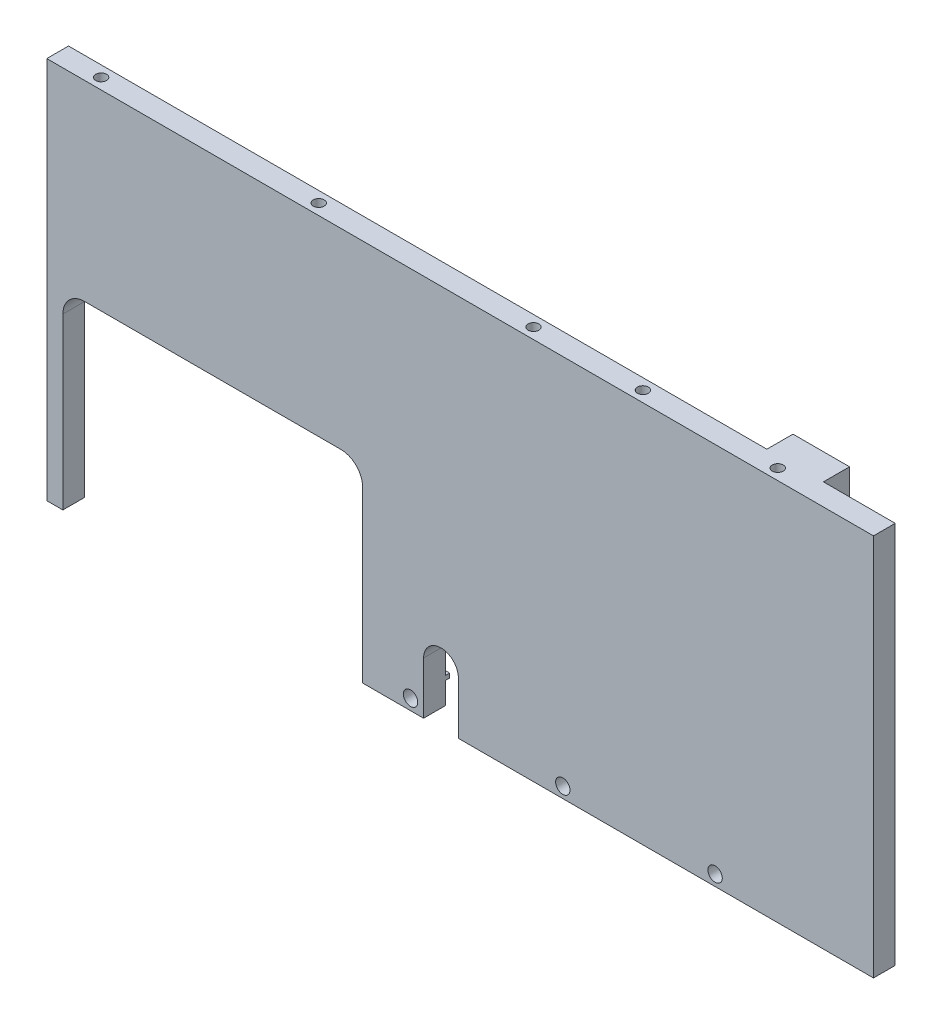
from build123d import *

# Parameters (mm, degrees)
SKETCH1_W              = 190
SKETCH1_H              = 88
BOSS_EXTRUDE1_DEPTH    = 5
SKETCH2_W              = 13
SKETCH2_H              = 83
BOSS_EXTRUDE2_DEPTH    = 6
BOSS_EXTRUDE3_DEPTH    = 1
SKETCH7_R              = 1.65
CUT_EXTRUDE3_DEPTH     = 6
FILLET3_R              = 2
HOLE_WIZARD_M3_1_D     = 2.5
HOLE_WIZARD_M3_1_DEPTH = 8.5
HOLE_WIZARD_M3_1_TIP   = 0.751075774
CUT_EXTRUDE_START      = -5
CUT_EXTRUDE_1_DEPTH    = 12
SKETCH_4_W             = 68.9
SKETCH_4_H             = 44
CUT_EXTRUDE_2_DEPTH    = 12
FILLET_1_R             = 5


with BuildPart() as part:
    # Sketch1 → Boss-Extrude1 (new body)
    with BuildSketch(Plane.XY):
        Rectangle(SKETCH1_W, SKETCH1_H)
    extrude(amount=BOSS_EXTRUDE1_DEPTH)

    # Sketch2 → Boss-Extrude2 (add)
    with BuildSketch(Plane(origin=(0, 0, 0), x_dir=(-1, 0, 0), z_dir=(0, 0, -1))):
        with Locations((-72, 2.5)):
            Rectangle(SKETCH2_W, SKETCH2_H)
    extrude(amount=BOSS_EXTRUDE2_DEPTH)

    # Sketch4 → Boss-Extrude3 (add)
    with BuildSketch(Plane(origin=(0, 0, 0), x_dir=(-1, 0, 0), z_dir=(0, 0, -1))):
        Polygon((-65.5, -38), (14, -38), (14, -34), (15, -34), (15, -39), (-65.5, -39), align=None)
    extrude(amount=BOSS_EXTRUDE3_DEPTH)

    # Sketch7 → Cut-Extrude3 (cut, through all)
    with BuildSketch(Plane(origin=(0, 0, 0), x_dir=(-1, 0, 0), z_dir=(0, 0, -1))):
        with Locations((-58.6, -41.5)):
            Circle(SKETCH7_R)
        with Locations((-23.6, -41.5)):
            Circle(SKETCH7_R)
        with Locations((11.4, -41.5)):
            Circle(SKETCH7_R)
    extrude(amount=-CUT_EXTRUDE3_DEPTH, mode=Mode.SUBTRACT)

    # Fillet3
    fillet3_edges = [part.edges().sort_by_distance(p)[0] for p in [
        (-14, -38, -0.5),
    ]]
    fillet(fillet3_edges, radius=FILLET3_R)

    # M3 螺纹孔1
    with Locations(Plane(origin=(-85, 44, 2.5), x_dir=(0, 0, 1), z_dir=(0, 1, 0))):
        with Locations((0, 0), (0, 50), (0, 99.373308098), (0, 124.5), (0, 155.5)):
            Hole(HOLE_WIZARD_M3_1_D / 2, depth=HOLE_WIZARD_M3_1_DEPTH)
            with Locations((0, 0, -(HOLE_WIZARD_M3_1_DEPTH + HOLE_WIZARD_M3_1_TIP / 2))):  # 118° drill point
                Cone(0, HOLE_WIZARD_M3_1_D / 2, HOLE_WIZARD_M3_1_TIP, mode=Mode.SUBTRACT)

    # 草图3 → 切除-拉伸1 (cut, through all)
    with BuildSketch(Plane(origin=(0, 0, 0), x_dir=(-1, 0, 0), z_dir=(0, 0, -1)).offset(CUT_EXTRUDE_START)):
        with BuildLine():
            Line((0.4, -44), (0.4, -32))
            ThreePointArc((0.4, -32), (4.4, -28), (8.4, -32))
            Line((8.4, -32), (8.4, -44))
            Line((8.4, -44), (0.4, -44))
        make_face()
    extrude(amount=CUT_EXTRUDE_1_DEPTH, mode=Mode.SUBTRACT)

    # 草图4 → 切除-拉伸2 (cut, through all)
    with BuildSketch(Plane.XY.offset(5)):
        with Locations((-56.85, -22)):
            Rectangle(SKETCH_4_W, SKETCH_4_H)
    extrude(amount=-CUT_EXTRUDE_2_DEPTH, mode=Mode.SUBTRACT)

    # 圆角1
    fillet_1_edges = [part.edges().sort_by_distance(p)[0] for p in [
        (-91.3, 0, 2.5),
        (-22.4, 0, 2.5),
    ]]
    fillet(fillet_1_edges, radius=FILLET_1_R)


solid = part.part
